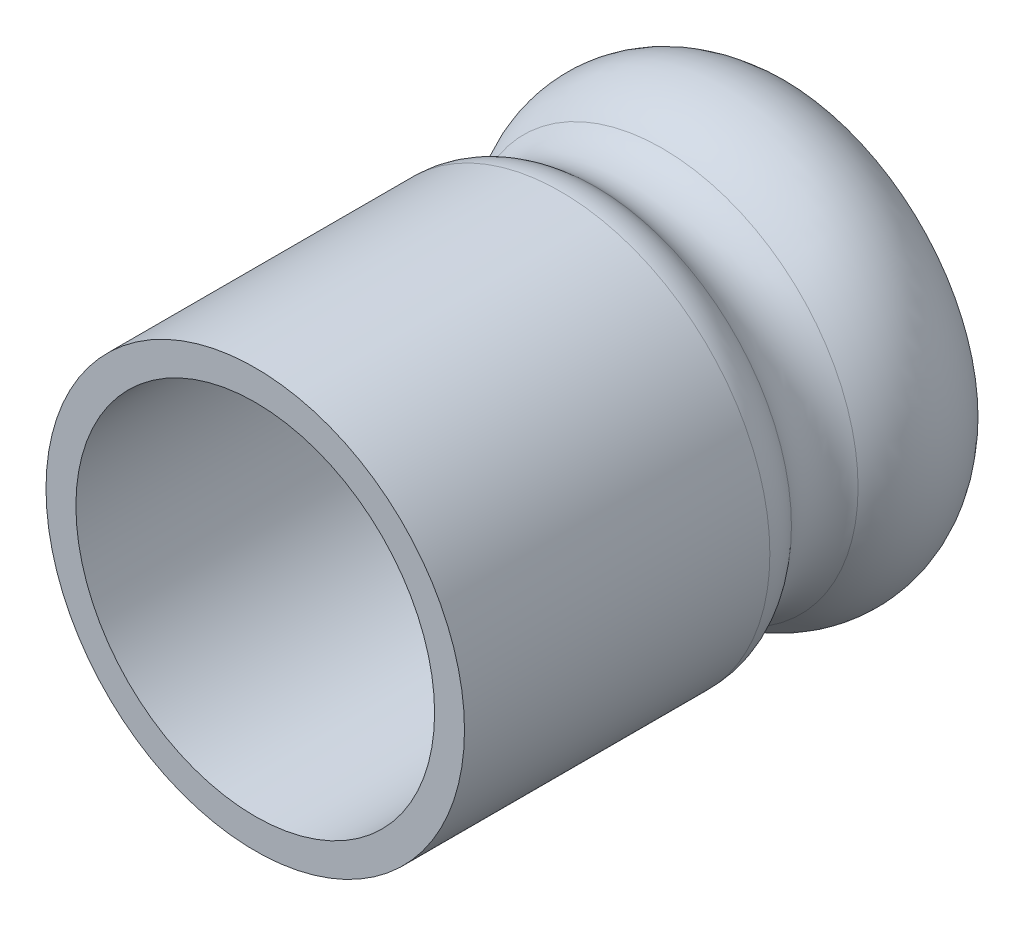
from build123d import *


with BuildPart() as part:
    # 草图2 → 旋转1 (revolve)
    with BuildSketch(Plane(origin=(0, 0, 0), x_dir=(1, 0, 0), z_dir=(0, 1, 0))):
        with BuildLine():
            ThreePointArc((13.104115055, 22.770530099), (12.25, 25), (13.104115055, 27.229469901))
            ThreePointArc((13.104115055, 27.229469901), (14.639719012, 31.287170848), (13.038257502, 35.319333731))
            Line((13.038257502, 35.319333731), (10, 35))
            ThreePointArc((10, 35), (12.519423129, 32.212719337), (11.616049309, 28.565755924))
            ThreePointArc((11.616049309, 28.565755924), (10.25, 25), (11.616049309, 21.434244076))
            ThreePointArc((11.616049309, 21.434244076), (11.900727305, 20.968651416), (12, 20.432029558))
            Line((12, 20.432029558), (12, 0))
            Line((12, 0), (14, 0))
            Line((14, 0), (14, 20.432029558))
            ThreePointArc((14, 20.432029558), (13.768363711, 21.684147226), (13.104115055, 22.770530099))
        make_face()
    revolve(axis=Axis((0, 0, 0), (0, 0, -1)))


solid = part.part
